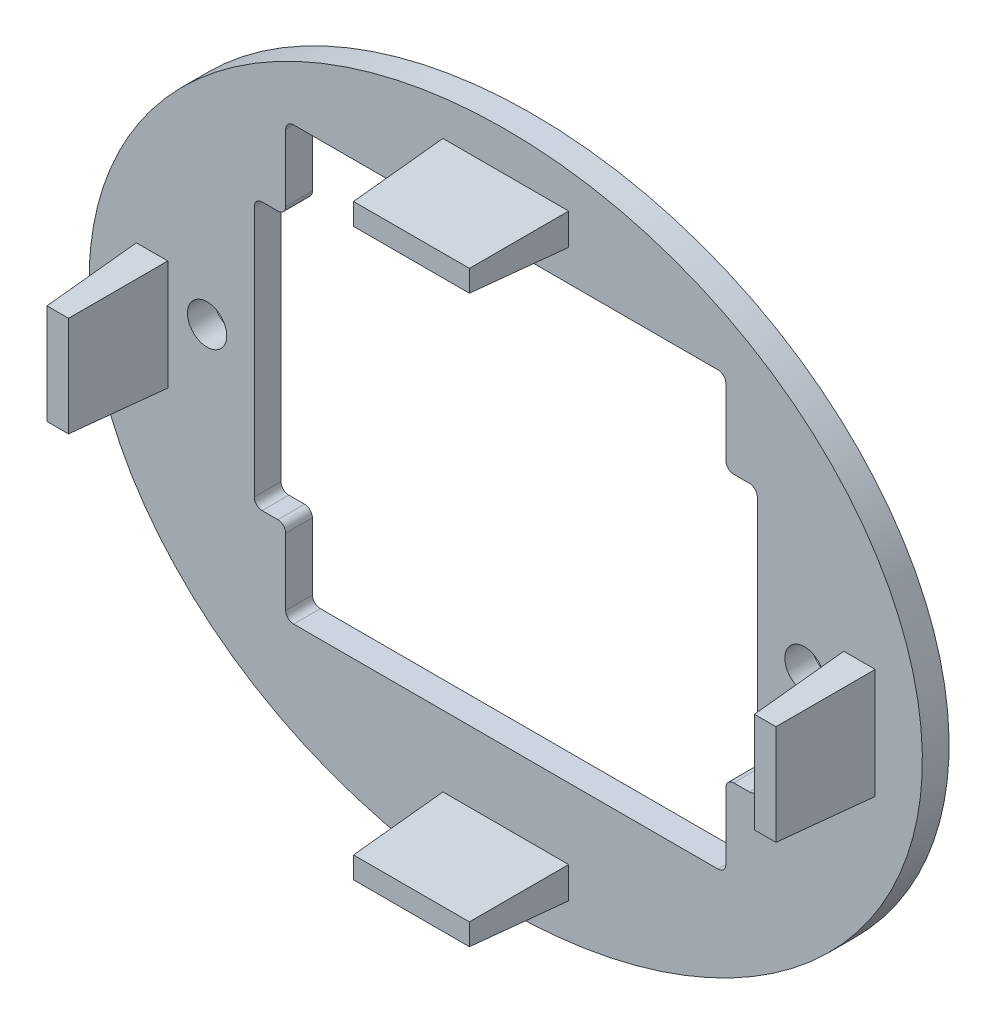
from build123d import *

# Parameters (mm, degrees)
SKETCH1_RX          = 26.5
SKETCH1_RY          = 21.5
SKETCH1_R           = 1.25
BOSS_EXTRUDE1_DEPTH = 1.7
FILLET1_R           = 0.5
SKETCH2_W           = 2
SKETCH2_H           = 7
SKETCH2_W_2         = 8
SKETCH2_H_2         = 2
BOSS_EXTRUDE2_DEPTH = 6
BOSS_EXTRUDE2_TAPER = 3


with BuildPart() as part:
    # Sketch1 → Boss-Extrude1 (new body)
    with BuildSketch(Plane.XY):
        with Locations(Location((0, 0), (0, 0, 180))):
            Ellipse(SKETCH1_RX, SKETCH1_RY)
        with Locations((-19, 1.25)):
            Circle(SKETCH1_R, mode=Mode.SUBTRACT)
        with Locations((19, 1.25)):
            Circle(SKETCH1_R, mode=Mode.SUBTRACT)
        Polygon((-14, 15), (14, 15), (14, 9.75), (16, 9.75), (16, -7.25), (14, -7.25), (14, -12.5), (-14, -12.5), (-14, -7.25), (-16, -7.25), (-16, 9.75), (-14, 9.75), align=None, mode=Mode.SUBTRACT)
    extrude(amount=BOSS_EXTRUDE1_DEPTH)

    # Fillet1
    fillet1_edges = [part.edges().sort_by_distance(p)[0] for p in [
        (-14, 15, 0.85),
        (-14, 9.75, 0.85),
        (-16, 9.75, 0.85),
        (-16, -7.25, 0.85),
        (-14, -7.25, 0.85),
        (-14, -12.5, 0.85),
        (14, -12.5, 0.85),
        (14, -7.25, 0.85),
        (16, -7.25, 0.85),
        (16, 9.75, 0.85),
        (14, 9.75, 0.85),
        (14, 15, 0.85),
    ]]
    fillet(fillet1_edges, radius=FILLET1_R)

    # Sketch2 → Boss-Extrude2 (add)
    with BuildSketch(Plane.XY.offset(1.7)):
        with Locations((-22.5, 0)):
            Rectangle(SKETCH2_W, SKETCH2_H)
        with Locations((0, 18)):
            Rectangle(SKETCH2_W_2, SKETCH2_H_2)
        with Locations((0, -18)):
            Rectangle(SKETCH2_W_2, SKETCH2_H_2)
        with Locations((22.5, 0)):
            Rectangle(SKETCH2_W, SKETCH2_H)
    extrude(amount=BOSS_EXTRUDE2_DEPTH, taper=BOSS_EXTRUDE2_TAPER)


solid = part.part
